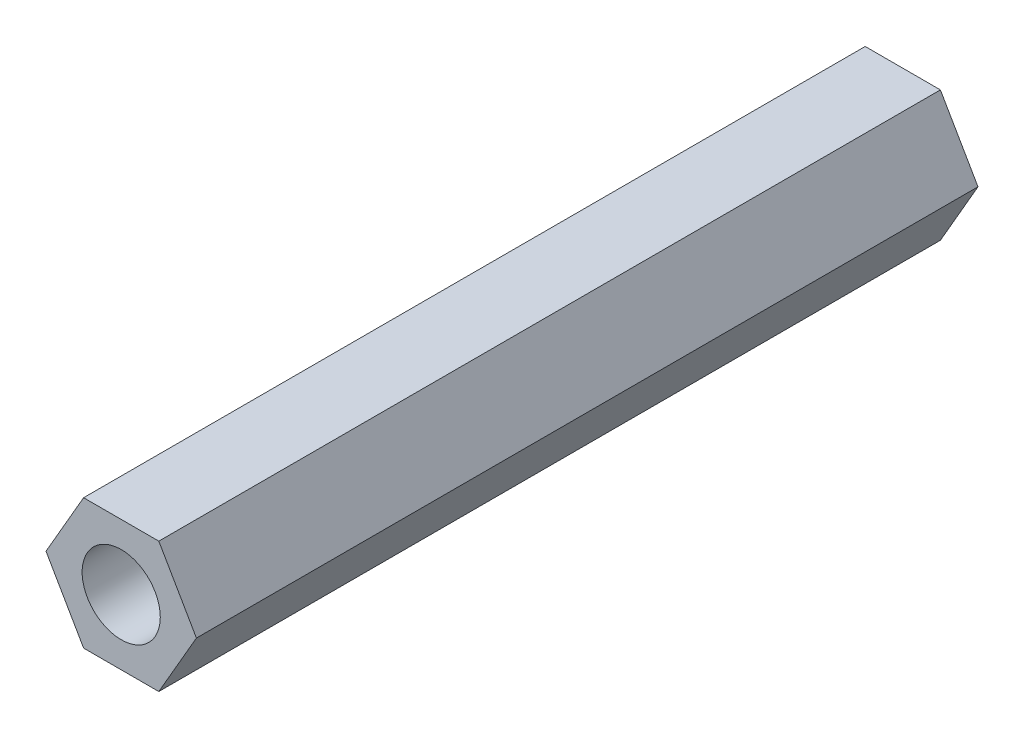
from build123d import *

# Parameters (mm, degrees)
SKETCH_1_R      = 1.5
EXTRUDE_1_DEPTH = 30


with BuildPart() as part:
    # 草图1 → 凸台-拉伸1 (new body)
    with BuildSketch(Plane.XY):
        Polygon((1.443375673, -2.5), (2.886751346, 0), (1.443375673, 2.5), (-1.443375673, 2.5), (-2.886751346, 0), (-1.443375673, -2.5), align=None)
        Circle(SKETCH_1_R, mode=Mode.SUBTRACT)
    extrude(amount=EXTRUDE_1_DEPTH)


solid = part.part
